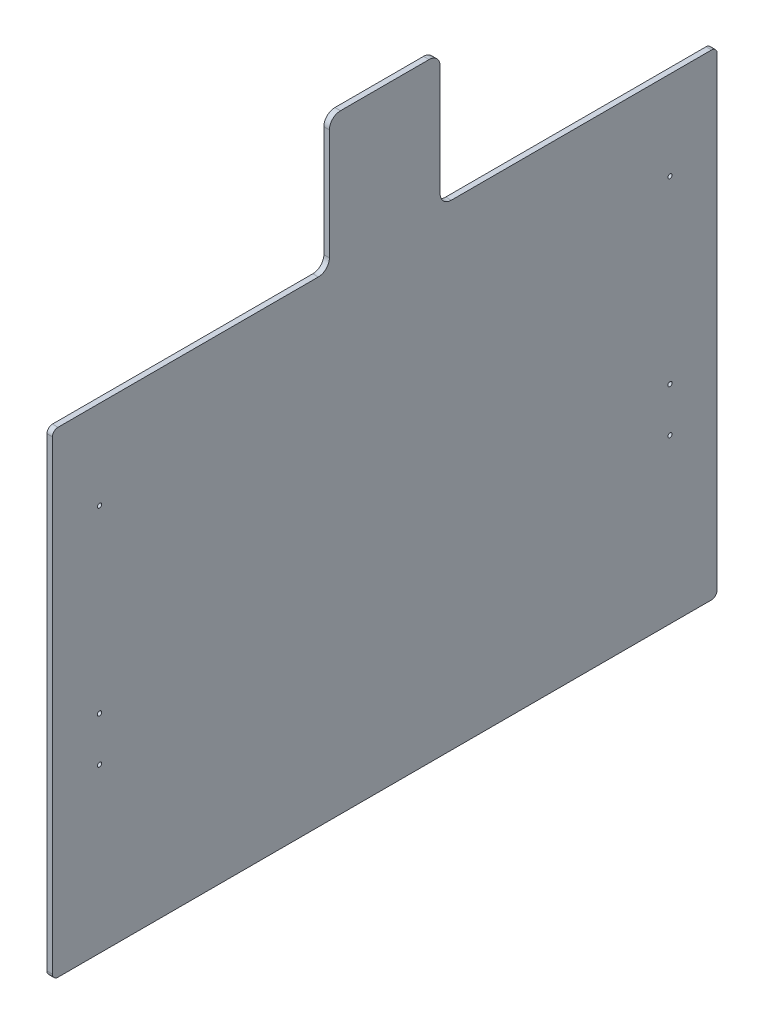
from build123d import *

# Parameters (mm, degrees)
SKETCH1_R           = 2.45745
BOSS_EXTRUDE1_DEPTH = 6.35


with BuildPart() as part:
    # Sketch1 → Boss-Extrude1 (new body)
    with BuildSketch(Plane(origin=(0, 0, 0), x_dir=(0, 0, -1), z_dir=(1, 0, 0))):
        with BuildLine():
            Line((457.2, 546.1), (755.65, 546.1))
            ThreePointArc((755.65, 546.1), (760.140128061, 544.240128061), (762, 539.75))
            Line((762, 539.75), (762, 6.35))
            ThreePointArc((762, 6.35), (760.140128061, 1.859871939), (755.65, 0))
            Line((755.65, 0), (6.35, 0))
            ThreePointArc((6.35, 0), (1.859871939, 1.859871939), (0, 6.35))
            Line((0, 6.35), (0, 539.75))
            ThreePointArc((0, 539.75), (1.859871939, 544.240128061), (6.35, 546.1))
            Line((6.35, 546.1), (304.8, 546.1))
            ThreePointArc((304.8, 546.1), (313.780256121, 549.819743879), (317.5, 558.8))
            Line((317.5, 558.8), (317.5, 685.8))
            ThreePointArc((317.5, 685.8), (321.219743879, 694.780256121), (330.2, 698.5))
            Line((330.2, 698.5), (431.8, 698.5))
            ThreePointArc((431.8, 698.5), (440.780256121, 694.780256121), (444.5, 685.8))
            Line((444.5, 685.8), (444.5, 558.8))
            ThreePointArc((444.5, 558.8), (448.219743879, 549.819743879), (457.2, 546.1))
        make_face()
        with Locations((53.975, 444.5)):
            Circle(SKETCH1_R, mode=Mode.SUBTRACT)
        with Locations((708.025, 444.5)):
            Circle(SKETCH1_R, mode=Mode.SUBTRACT)
        with Locations((708.025, 238.125)):
            Circle(SKETCH1_R, mode=Mode.SUBTRACT)
        with Locations((53.975, 238.125)):
            Circle(SKETCH1_R, mode=Mode.SUBTRACT)
        with Locations((53.975, 187.325)):
            Circle(SKETCH1_R, mode=Mode.SUBTRACT)
        with Locations((708.025, 187.325)):
            Circle(SKETCH1_R, mode=Mode.SUBTRACT)
    extrude(amount=BOSS_EXTRUDE1_DEPTH)


solid = part.part
